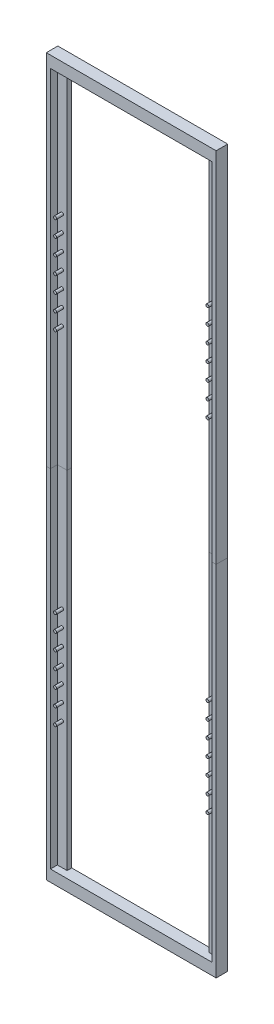
from build123d import *

# Parameters (mm, degrees)
SKETCH1_W           = 310
SKETCH1_H           = 73.5
SKETCH1_W_2         = 300
SKETCH1_H_2         = 61.5
BOSS_EXTRUDE1_DEPTH = 5
SKETCH2_W           = 4.2
SKETCH2_H           = 300
CUT_EXTRUDE1_DEPTH  = 3
SKETCH7_R           = 0.65
BOSS_EXTRUDE2_DEPTH = 3


with BuildPart() as part:
    # Sketch1 → Boss-Extrude1 (new body)
    with BuildSketch(Plane(origin=(0, 0, 0), x_dir=(0, 1, 0), z_dir=(0, 0, 1))):
        Rectangle(SKETCH1_W, SKETCH1_H)
        Rectangle(SKETCH1_W_2, SKETCH1_H_2, mode=Mode.SUBTRACT)
    extrude(amount=BOSS_EXTRUDE1_DEPTH)

    # Sketch2 → Cut-Extrude1 (cut)
    with BuildSketch(Plane.XY.offset(5)):
        with Locations((-32.85, 0)):
            Rectangle(SKETCH2_W, SKETCH2_H)
        with Locations((32.85, 0)):
            Rectangle(SKETCH2_W, SKETCH2_H)
    extrude(amount=-CUT_EXTRUDE1_DEPTH, mode=Mode.SUBTRACT)

    # Sketch7 → Boss-Extrude2 (add)
    with BuildSketch(Plane.XY.offset(2)):
        with Locations((-32.95, -67)):
            Circle(SKETCH7_R)
        with Locations((-32.95, -53)):
            Circle(SKETCH7_R)
        with Locations((-32.95, 53)):
            Circle(SKETCH7_R)
        with Locations((-32.95, 67)):
            Circle(SKETCH7_R)
        with Locations((32.95, 67)):
            Circle(SKETCH7_R)
        with Locations((32.95, 53)):
            Circle(SKETCH7_R)
        with Locations((32.95, -53)):
            Circle(SKETCH7_R)
        with Locations((32.95, -67)):
            Circle(SKETCH7_R)
        with Locations((32.95, -60)):
            Circle(SKETCH7_R)
        with Locations((32.95, -74)):
            Circle(SKETCH7_R)
        with Locations((32.95, -81)):
            Circle(SKETCH7_R)
        with Locations((32.95, -88)):
            Circle(SKETCH7_R)
        with Locations((32.95, -95)):
            Circle(SKETCH7_R)
        with Locations((-32.95, -74)):
            Circle(SKETCH7_R)
        with Locations((-32.95, -60)):
            Circle(SKETCH7_R)
        with Locations((-32.95, -81)):
            Circle(SKETCH7_R)
        with Locations((-32.95, -88)):
            Circle(SKETCH7_R)
        with Locations((-32.95, -95)):
            Circle(SKETCH7_R)
        with Locations((-32.95, 74)):
            Circle(SKETCH7_R)
        with Locations((-32.95, 60)):
            Circle(SKETCH7_R)
        with Locations((-32.95, 81)):
            Circle(SKETCH7_R)
        with Locations((-32.95, 88)):
            Circle(SKETCH7_R)
        with Locations((-32.95, 95)):
            Circle(SKETCH7_R)
        with Locations((32.95, 60)):
            Circle(SKETCH7_R)
        with Locations((32.95, 74)):
            Circle(SKETCH7_R)
        with Locations((32.95, 81)):
            Circle(SKETCH7_R)
        with Locations((32.95, 88)):
            Circle(SKETCH7_R)
        with Locations((32.95, 95)):
            Circle(SKETCH7_R)
    extrude(amount=BOSS_EXTRUDE2_DEPTH)


with BuildPart() as body_2:
    # Split1: the piece on the far side of the plane
    add(part.part)
    split(bisect_by=Plane(origin=(0, 0, 0), x_dir=(0, 0, -1), z_dir=(0, -1, 0)), keep=Keep.BOTTOM)


with BuildPart() as part_1:
    add(part.part)

    # Split1
    split(bisect_by=Plane(origin=(0, 0, 0), x_dir=(0, 0, -1), z_dir=(0, -1, 0)), keep=Keep.TOP)


solid = Compound([body_2.part, part_1.part])
